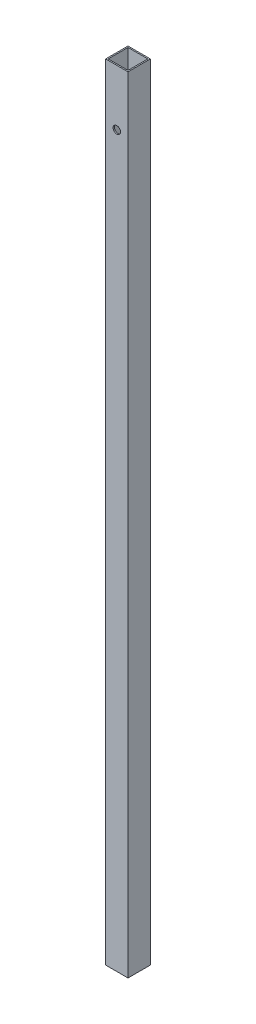
from build123d import *

# Parameters (mm, degrees)
SKETCH1_W           = 18
SKETCH1_H           = 18
SKETCH1_W_2         = 16
SKETCH1_H_2         = 16
BOSS_EXTRUDE1_DEPTH = 632
SKETCH2_R           = 3
CUT_EXTRUDE1_DEPTH  = 993


with BuildPart() as part:
    # Sketch1 → Boss-Extrude1 (new body)
    with BuildSketch(Plane(origin=(0, 0, 0), x_dir=(1, 0, 0), z_dir=(0, 1, 0))):
        Rectangle(SKETCH1_W, SKETCH1_H)
        Rectangle(SKETCH1_W_2, SKETCH1_H_2, mode=Mode.SUBTRACT)
    extrude(amount=BOSS_EXTRUDE1_DEPTH)

    # Sketch2 → Cut-Extrude1 (cut)
    with BuildSketch(Plane.XY.offset(9)):
        with Locations((0, 587)):
            Circle(SKETCH2_R)
    extrude(amount=-CUT_EXTRUDE1_DEPTH, mode=Mode.SUBTRACT)


solid = part.part
